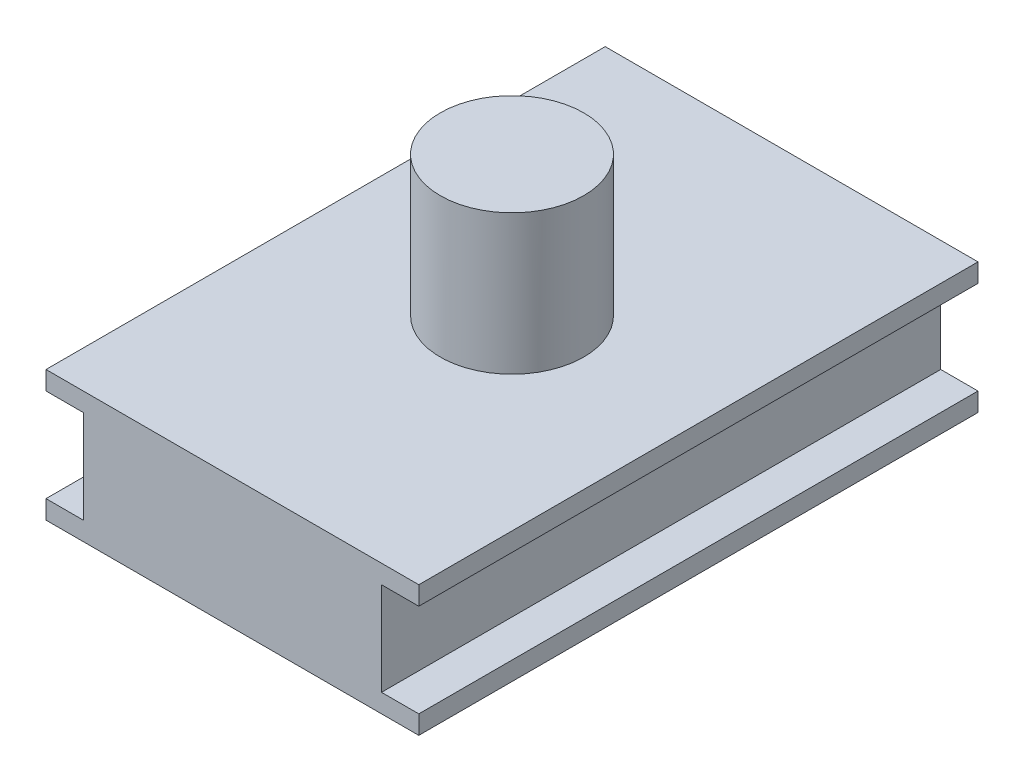
from build123d import *

# Parameters (mm, degrees)
SKETCH1_W           = 20
SKETCH1_H           = 30
BOSS_EXTRUDE1_DEPTH = 7
SKETCH2_W           = 30
SKETCH2_H           = 5
CUT_EXTRUDE1_DEPTH  = 2
SKETCH3_W           = 30
SKETCH3_H           = 5
CUT_EXTRUDE2_DEPTH  = 2
SKETCH4_R           = 3.85
BOSS_EXTRUDE2_DEPTH = 7.5


with BuildPart() as part:
    # Sketch1 → Boss-Extrude1 (new body)
    with BuildSketch(Plane(origin=(0, 0, 0), x_dir=(1, 0, 0), z_dir=(0, 1, 0))):
        Rectangle(SKETCH1_W, SKETCH1_H)
    extrude(amount=BOSS_EXTRUDE1_DEPTH)

    # Sketch2 → Cut-Extrude1 (cut)
    with BuildSketch(Plane(origin=(10, 0, 0), x_dir=(0, 0, -1), z_dir=(1, 0, 0))):
        with Locations((0, 3.5)):
            Rectangle(SKETCH2_W, SKETCH2_H)
    extrude(amount=-CUT_EXTRUDE1_DEPTH, mode=Mode.SUBTRACT)

    # Sketch3 → Cut-Extrude2 (cut)
    with BuildSketch(Plane.ZY.offset(10)):
        with Locations((0, 3.5)):
            Rectangle(SKETCH3_W, SKETCH3_H)
    extrude(amount=-CUT_EXTRUDE2_DEPTH, mode=Mode.SUBTRACT)

    # Sketch4 → Boss-Extrude2 (add)
    with BuildSketch(Plane(origin=(0, 7, 0), x_dir=(1, 0, 0), z_dir=(0, 1, 0))):
        Circle(SKETCH4_R)
    extrude(amount=BOSS_EXTRUDE2_DEPTH)


solid = part.part
